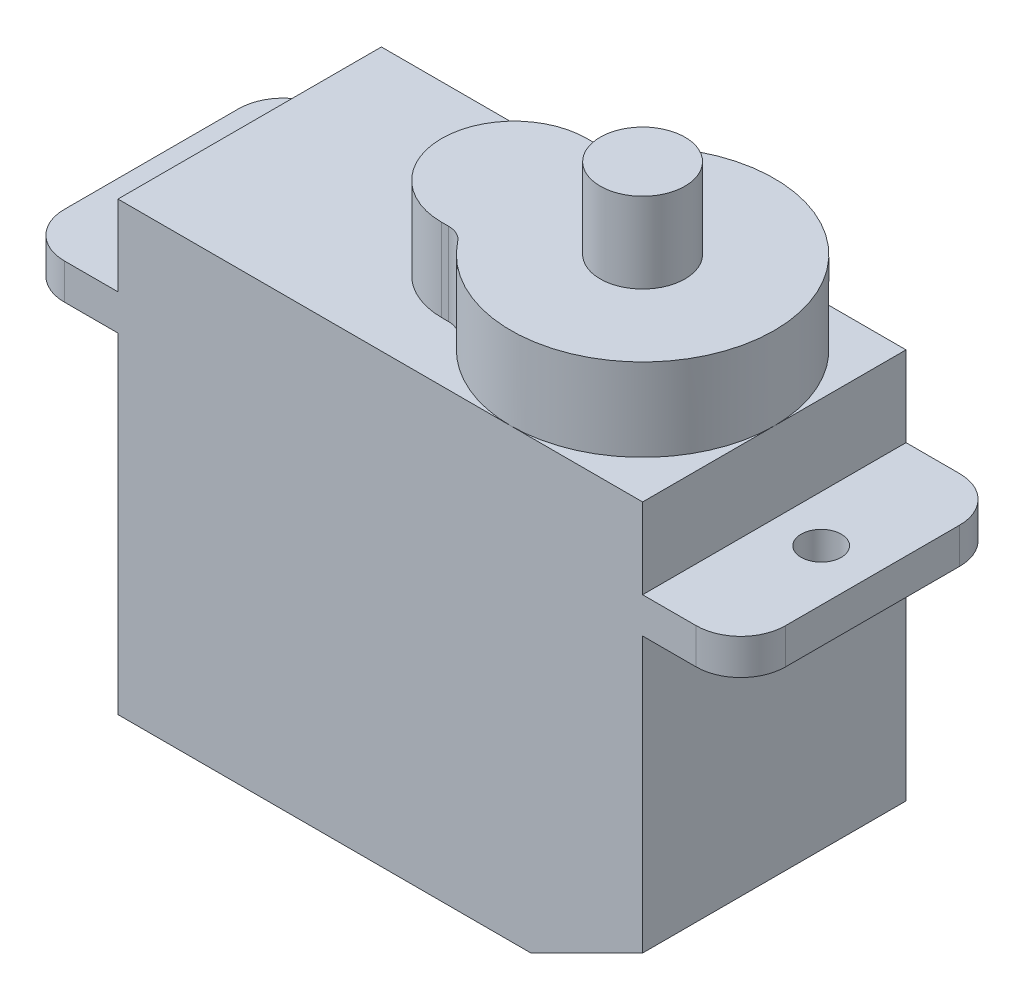
from build123d import *

# Parameters (mm, degrees)
DODANIE_WYCI_GNI_CIE1_DEPTH = 11.8
SZKIC2_R                    = 0.9
WYTNIJ_WYCI_GNI_CIE1_DEPTH  = 11.8
ZAOKR_GLENIE1_R             = 2
DODANIE_WYCI_GNI_CIE2_DEPTH = 3.7
SZKIC4_R                    = 1.9
DODANIE_WYCI_GNI_CIE3_DEPTH = 3.6


with BuildPart() as part:
    # Szkic1 → Dodanie-wyciągnięcie1 (new body)
    with BuildSketch(Plane.XY):
        Polygon((0, 0), (0, 14.8), (-4.4, 14.8), (-4.4, 16.4), (0, 16.4), (0, 20), (23.5, 20), (23.5, 16.4), (27.9, 16.4), (27.9, 14.8), (23.5, 14.8), (23.5, 2.5), (18.5, 0), align=None)
    extrude(amount=DODANIE_WYCI_GNI_CIE1_DEPTH)

    # Szkic2 → Wytnij-wyciągnięcie1 (cut)
    with BuildSketch(Plane(origin=(0, 16.4, 0), x_dir=(1, 0, 0), z_dir=(0, 1, 0))):
        with Locations((-2.1, -5.9)):
            Circle(SZKIC2_R)
        with Locations((25.6, -5.9)):
            Circle(SZKIC2_R)
    extrude(amount=-WYTNIJ_WYCI_GNI_CIE1_DEPTH, mode=Mode.SUBTRACT)

    # Zaokrąglenie1
    zaokr_glenie1_edges = [part.edges().sort_by_distance(p)[0] for p in [
        (-4.4, 15.6, 0),
        (27.9, 15.6, 0),
        (27.9, 15.6, 11.8),
        (-4.4, 15.6, 11.8),
    ]]
    fillet(zaokr_glenie1_edges, radius=ZAOKR_GLENIE1_R)

    # Szkic3 → Dodanie-wyciągnięcie2 (add)
    with BuildSketch(Plane(origin=(0, 20, 0), x_dir=(1, 0, 0), z_dir=(0, 1, 0))):
        with BuildLine():
            Line((11.85, -2.65), (12.164238784, -2.65))
            ThreePointArc((12.164238784, -2.65), (12.602449904, -2.548872079), (12.952030264, -2.265942029))
            ThreePointArc((12.952030264, -2.265942029), (23.5, -5.9), (12.952030264, -9.534057971))
            ThreePointArc((12.952030264, -9.534057971), (12.602449904, -9.251127921), (12.164238784, -9.15))
            Line((12.164238784, -9.15), (11.85, -9.15))
            ThreePointArc((11.85, -9.15), (8.6, -5.9), (11.85, -2.65))
        make_face()
    extrude(amount=DODANIE_WYCI_GNI_CIE2_DEPTH)

    # Szkic4 → Dodanie-wyciągnięcie3 (add)
    with BuildSketch(Plane(origin=(0, 23.7, 0), x_dir=(1, 0, 0), z_dir=(0, 1, 0))):
        with Locations((17.6, -5.9)):
            Circle(SZKIC4_R)
    extrude(amount=DODANIE_WYCI_GNI_CIE3_DEPTH)


solid = part.part
